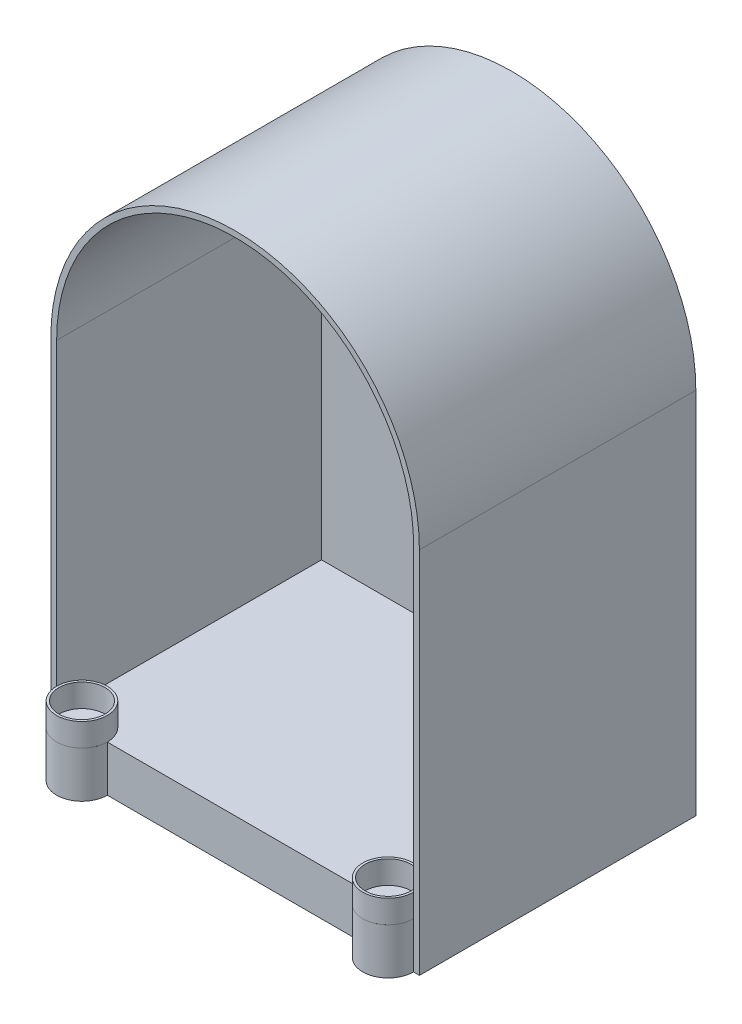
from build123d import *

# Parameters (mm, degrees)
BOSS_EXTRUDE1_DEPTH    = 152.4
CUT_EXTRUDE1_DEPTH     = 146.05
BOSS_EXTRUDE4_DEPTH    = 25.4
SKETCH5_R              = 13.97
BOSS_EXTRUDE10_DEPTH   = 12.7
BOSS_EXTRUDE10_2_DEPTH = 12.7
SKETCH6_R              = 12.7
CUT_EXTRUDE2_DEPTH     = 12.7


with BuildPart() as part:
    # Sketch1 → Boss-Extrude1 (new body)
    with BuildSketch(Plane.XY):
        with BuildLine():
            Line((0, 203.2), (0, 0))
            Line((0, 0), (203.2, 0))
            Line((203.2, 0), (203.2, 203.2))
            ThreePointArc((203.2, 203.2), (101.6, 304.8), (0, 203.2))
        make_face()
    extrude(amount=BOSS_EXTRUDE1_DEPTH)

    # Sketch2 → Cut-Extrude1 (cut)
    with BuildSketch(Plane.XY.offset(152.4)):
        with BuildLine():
            Line((3.175, 203.2), (3.175, 25.4))
            Line((3.175, 25.4), (200.025, 25.4))
            Line((200.025, 25.4), (200.025, 203.2))
            ThreePointArc((200.025, 203.2), (101.6, 301.625), (3.175, 203.2))
        make_face()
    extrude(amount=-CUT_EXTRUDE1_DEPTH, mode=Mode.SUBTRACT)

    # Sketch4 → Boss-Extrude4 (add)
    with BuildSketch(Plane(origin=(0, 0, 0), x_dir=(1, 0, 0), z_dir=(0, 1, 0))):
        with BuildLine():
            ThreePointArc((31.115, -152.4), (17.145, -166.37), (3.175, -152.4))
            Line((3.175, -152.4), (31.115, -152.4))
        make_face()
        with BuildLine():
            Line((171.958, -152.4), (199.898, -152.4))
            ThreePointArc((199.898, -152.4), (185.928, -166.37), (171.958, -152.4))
        make_face()
    extrude(amount=BOSS_EXTRUDE4_DEPTH)


with BuildPart() as body_2:
    # Sketch5 → Boss-Extrude10 (new body)
    with BuildSketch(Plane(origin=(0, 25.4, 0), x_dir=(1, 0, 0), z_dir=(0, 1, 0))):
        with Locations((17.145, -152.4)):
            Circle(SKETCH5_R)
    extrude(amount=BOSS_EXTRUDE10_DEPTH)


with BuildPart() as body_3:
    # Sketch5 → Boss-Extrude10 2 (new body)
    with BuildSketch(Plane(origin=(0, 25.4, 0), x_dir=(1, 0, 0), z_dir=(0, 1, 0))):
        with Locations((185.928, -152.4)):
            Circle(SKETCH5_R)
    extrude(amount=BOSS_EXTRUDE10_2_DEPTH)


with BuildPart() as cut_extrude2_tool:
    # Sketch6 → Cut-Extrude2 (new body)
    with BuildSketch(Plane(origin=(0, 38.1, 0), x_dir=(1, 0, 0), z_dir=(0, 1, 0))):
        with Locations((17.145, -152.4)):
            Circle(SKETCH6_R)
        with Locations((185.928, -152.4)):
            Circle(SKETCH6_R)
    extrude(amount=-CUT_EXTRUDE2_DEPTH)


with BuildPart() as body_2_1:
    add(body_2.part)

    # Cut-Extrude2: cut by cut_extrude2_tool
    add(cut_extrude2_tool.part, mode=Mode.SUBTRACT)


with BuildPart() as body_3_1:
    add(body_3.part)

    # Cut-Extrude2: cut by cut_extrude2_tool
    add(cut_extrude2_tool.part, mode=Mode.SUBTRACT)


solid = Compound([part.part, body_2_1.part, body_3_1.part])
